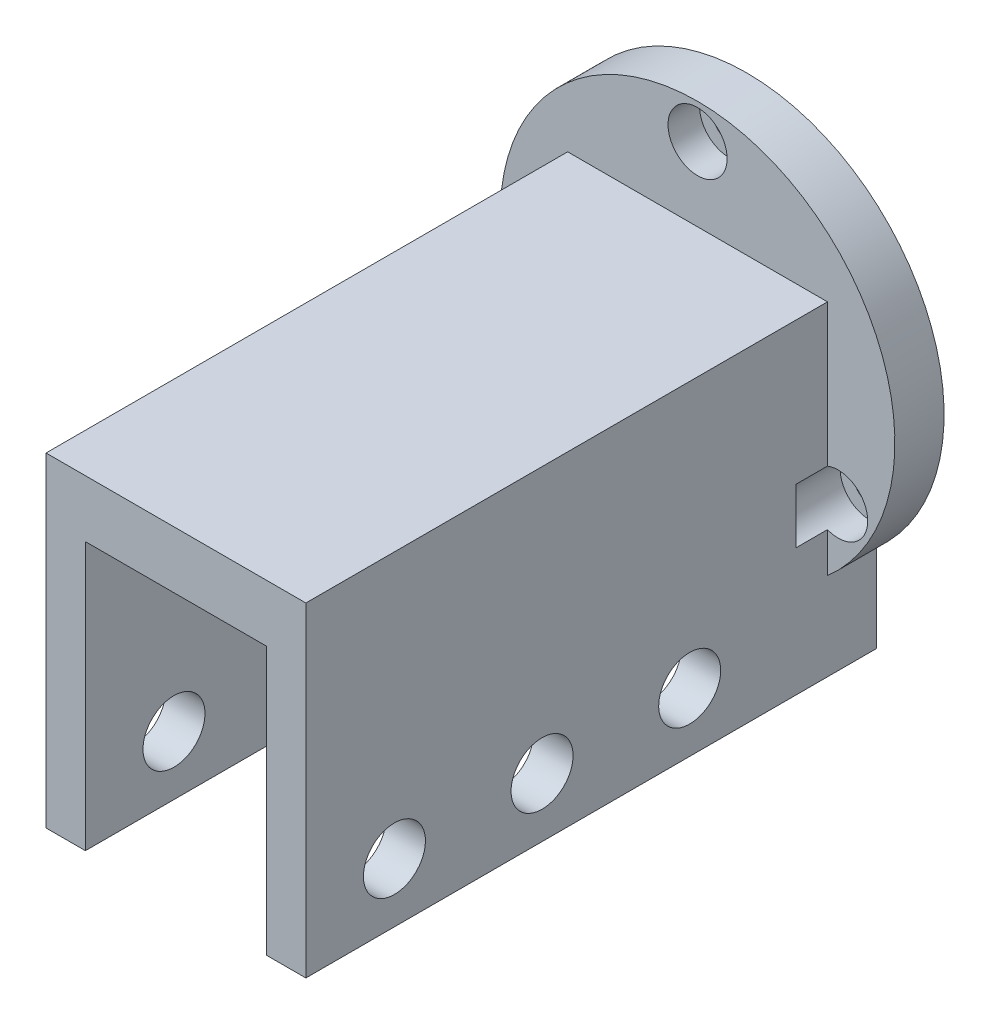
from build123d import *

# Parameters (mm, degrees)
EXTRUDE_1_DEPTH          = 24
CUT_EXTRUDE_2_REACH      = 50.6
SKETCH_3_R               = 3.15
SKETCH_4_W               = 18.4
SKETCH_4_H               = 17.2
SKETCH_4_H_2             = 10
EXTRUDE_2_DEPTH          = 10
SKETCH_4_3_W             = 18.4
SKETCH_4_3_H             = 17.2
CUT_EXTRUDE_4_DEPTH      = 5
SKETCH_4_5_W             = 18.4
SKETCH_4_5_H             = 10
CUT_EXTRUDE_6_DEPTH      = 2
SKETCH_2_R               = 20.05
SKETCH_2_R_2             = 1.6
EXTRUDE_3_DEPTH          = 5
SKETCH_7_R               = 1.6
CUT_EXTRUDE_7_DEPTH      = 77.51774304
SKETCH_8_R               = 3
CUT_EXTRUDE_8_DEPTH      = 3.2
CUT_EXTRUDE_8_DEPTH_BACK = 3.2


with BuildPart() as part:
    # 草圖1 → 填料-伸長1 (new, symmetric)
    with BuildSketch(Plane.XY):
        Polygon((0, 0), (0, 33), (26.4, 33), (26.4, 0), (22.4, 0), (22.4, 27.2), (4, 27.2), (4, 0), align=None)
    extrude(amount=EXTRUDE_1_DEPTH, both=True)

    # 除料-伸長2: up to this face of the body (flat: up to its plane)
    cut_extrude_2_end = Plane(part.part.faces().sort_by_distance((0, 16.5, 0))[0])
    # 草圖3 → 除料-伸長2 (cut, up to the picked face)
    with BuildSketch(Plane(origin=(26.4, 0, 0), x_dir=(0, 0, -1), z_dir=(1, 0, 0)), mode=Mode.PRIVATE) as cut_extrude_2_sk1:
        with Locations(Location((0, 6, 0), (0, 0, 90))):
            Circle(SKETCH_3_R)
    cut_extrude_2_tool1 = split(extrude(cut_extrude_2_sk1.sketch, amount=-CUT_EXTRUDE_2_REACH, mode=Mode.PRIVATE), bisect_by=cut_extrude_2_end, keep=Keep.BOTH, mode=Mode.PRIVATE)
    # 草圖3 → 除料-伸長2 (cut, up to the picked face)
    with BuildSketch(Plane(origin=(26.4, 0, 0), x_dir=(0, 0, -1), z_dir=(1, 0, 0)), mode=Mode.PRIVATE) as cut_extrude_2_sk2:
        with Locations(Location((15, 6, 0), (0, 0, 90))):
            Circle(SKETCH_3_R)
    cut_extrude_2_tool2 = split(extrude(cut_extrude_2_sk2.sketch, amount=-CUT_EXTRUDE_2_REACH, mode=Mode.PRIVATE), bisect_by=cut_extrude_2_end, keep=Keep.BOTH, mode=Mode.PRIVATE)
    # 草圖3 → 除料-伸長2 (cut, up to the picked face)
    with BuildSketch(Plane(origin=(26.4, 0, 0), x_dir=(0, 0, -1), z_dir=(1, 0, 0)), mode=Mode.PRIVATE) as cut_extrude_2_sk3:
        with Locations(Location((-15, 6, 0), (0, 0, 90))):
            Circle(SKETCH_3_R)
    cut_extrude_2_tool3 = split(extrude(cut_extrude_2_sk3.sketch, amount=-CUT_EXTRUDE_2_REACH, mode=Mode.PRIVATE), bisect_by=cut_extrude_2_end, keep=Keep.BOTH, mode=Mode.PRIVATE)
    add(cut_extrude_2_tool1.solids().sort_by(Axis((26.4, 6, 0), (-1, 0, 0)))[0], mode=Mode.SUBTRACT)
    add(cut_extrude_2_tool2.solids().sort_by(Axis((26.4, 6, -15), (-1, 0, 0)))[0], mode=Mode.SUBTRACT)
    add(cut_extrude_2_tool3.solids().sort_by(Axis((26.4, 6, 15), (-1, 0, 0)))[0], mode=Mode.SUBTRACT)

    # 草圖4 → 填料-伸長2 (add)
    with BuildSketch(Plane(origin=(0, 0, -24), x_dir=(-1, 0, 0), z_dir=(0, 0, -1))):
        Polygon((-4, 27.2), (-4, 0), (0, 0), (0, 33), (-26.4, 33), (-26.4, 0), (-22.4, 0), (-22.4, 27.2), align=None)
        with Locations((-13.2, 18.6)):
            Rectangle(SKETCH_4_W, SKETCH_4_H)
        with Locations((-13.2, 5)):
            Rectangle(SKETCH_4_W, SKETCH_4_H_2)
    extrude(amount=EXTRUDE_2_DEPTH)

    # 草圖4<3> → 除料-伸長4 (cut)
    with BuildSketch(Plane(origin=(0, 0, -24), x_dir=(-1, 0, 0), z_dir=(0, 0, -1))):
        with Locations((-13.2, 18.6)):
            Rectangle(SKETCH_4_3_W, SKETCH_4_3_H)
    extrude(amount=CUT_EXTRUDE_4_DEPTH, mode=Mode.SUBTRACT)

    # 草圖4<5> → 除料-伸長6 (cut)
    with BuildSketch(Plane(origin=(0, 0, -24), x_dir=(-1, 0, 0), z_dir=(0, 0, -1))):
        with Locations((-13.2, 5)):
            Rectangle(SKETCH_4_5_W, SKETCH_4_5_H)
    extrude(amount=CUT_EXTRUDE_6_DEPTH, mode=Mode.SUBTRACT)

    # 草圖2 → 填料-伸長3 (add)
    with BuildSketch(Plane(origin=(60.4, 53.6, -34), x_dir=(0, -1, 0), z_dir=(0, 0, 1))):
        with Locations((29.6, -47.2)):
            Circle(SKETCH_2_R)
        with Locations(Location((13.1, -47.2, 0), (0, 0, 90))):
            Circle(SKETCH_2_R_2, mode=Mode.SUBTRACT)
        with Locations((37.85, -32.910580838)):
            Circle(SKETCH_2_R_2, mode=Mode.SUBTRACT)
        with Locations((37.85, -61.489419162)):
            Circle(SKETCH_2_R_2, mode=Mode.SUBTRACT)
    extrude(amount=EXTRUDE_3_DEPTH)

    # 草圖7 → 除料-伸長7 (cut, through all)
    with BuildSketch(Plane.XY.offset(-29)):
        with Locations(Location((27.489419162, 15.75, 0), (0, 0, 227.087006542))):
            Circle(SKETCH_7_R)
        with Locations(Location((-1.089419162, 15.75, 0), (0, 0, 312.912993458))):
            Circle(SKETCH_7_R)
    extrude(amount=-CUT_EXTRUDE_7_DEPTH, mode=Mode.SUBTRACT)

    # 草圖8 → 除料-伸長8 (cut, two sides)
    with BuildSketch(Plane.XY.offset(-29)) as cut_extrude_8_sk:
        with Locations(Location((-1.089419162, 15.75, 0), (0, 0, 68.706857297))):
            Circle(SKETCH_8_R)
        with Locations(Location((27.489419162, 15.75, 0), (0, 0, 248.706857297))):
            Circle(SKETCH_8_R)
        with Locations((13.2, 40.5)):
            Circle(SKETCH_8_R)
    extrude(amount=CUT_EXTRUDE_8_DEPTH, mode=Mode.SUBTRACT)
    extrude(cut_extrude_8_sk.sketch, amount=-CUT_EXTRUDE_8_DEPTH_BACK, mode=Mode.SUBTRACT)


solid = part.part
